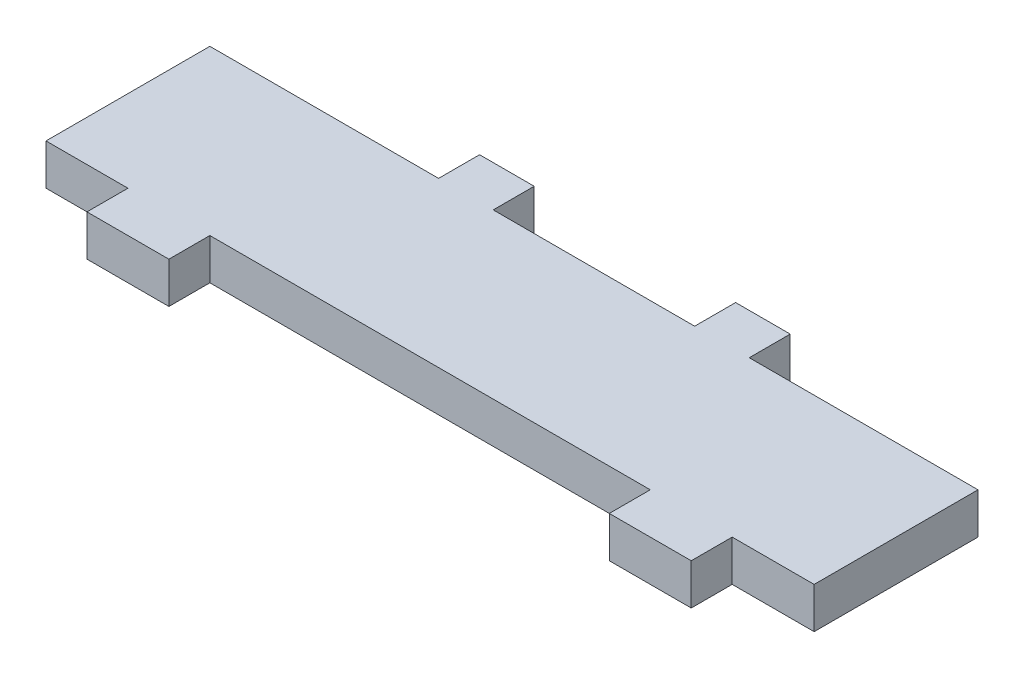
from build123d import *

# Parameters (mm, degrees)
SKETCH1_W           = 112.5
SKETCH1_H           = 24
BOSS_EXTRUDE1_DEPTH = 6
SKETCH2_W           = 8
SKETCH2_H           = 6
BOSS_EXTRUDE2_DEPTH = 6
SKETCH3_W           = 12
SKETCH3_H           = 6
BOSS_EXTRUDE3_DEPTH = 6


with BuildPart() as part:
    # Sketch1 → Boss-Extrude1 (new body)
    with BuildSketch(Plane(origin=(0, 0, 0), x_dir=(1, 0, 0), z_dir=(0, 1, 0))):
        Rectangle(SKETCH1_W, SKETCH1_H)
    extrude(amount=BOSS_EXTRUDE1_DEPTH)

    # Sketch2 → Boss-Extrude2 (add)
    with BuildSketch(Plane(origin=(0, 0, -12), x_dir=(-1, 0, 0), z_dir=(0, 0, -1))):
        with Locations((-18.75, 3)):
            Rectangle(SKETCH2_W, SKETCH2_H)
        with Locations((18.75, 3)):
            Rectangle(SKETCH2_W, SKETCH2_H)
    extrude(amount=BOSS_EXTRUDE2_DEPTH)

    # Sketch3 → Boss-Extrude3 (add)
    with BuildSketch(Plane.XY.offset(12)):
        with Locations((-38.25, 3)):
            Rectangle(SKETCH3_W, SKETCH3_H)
        with Locations((38.25, 3)):
            Rectangle(SKETCH3_W, SKETCH3_H)
    extrude(amount=BOSS_EXTRUDE3_DEPTH)


solid = part.part
